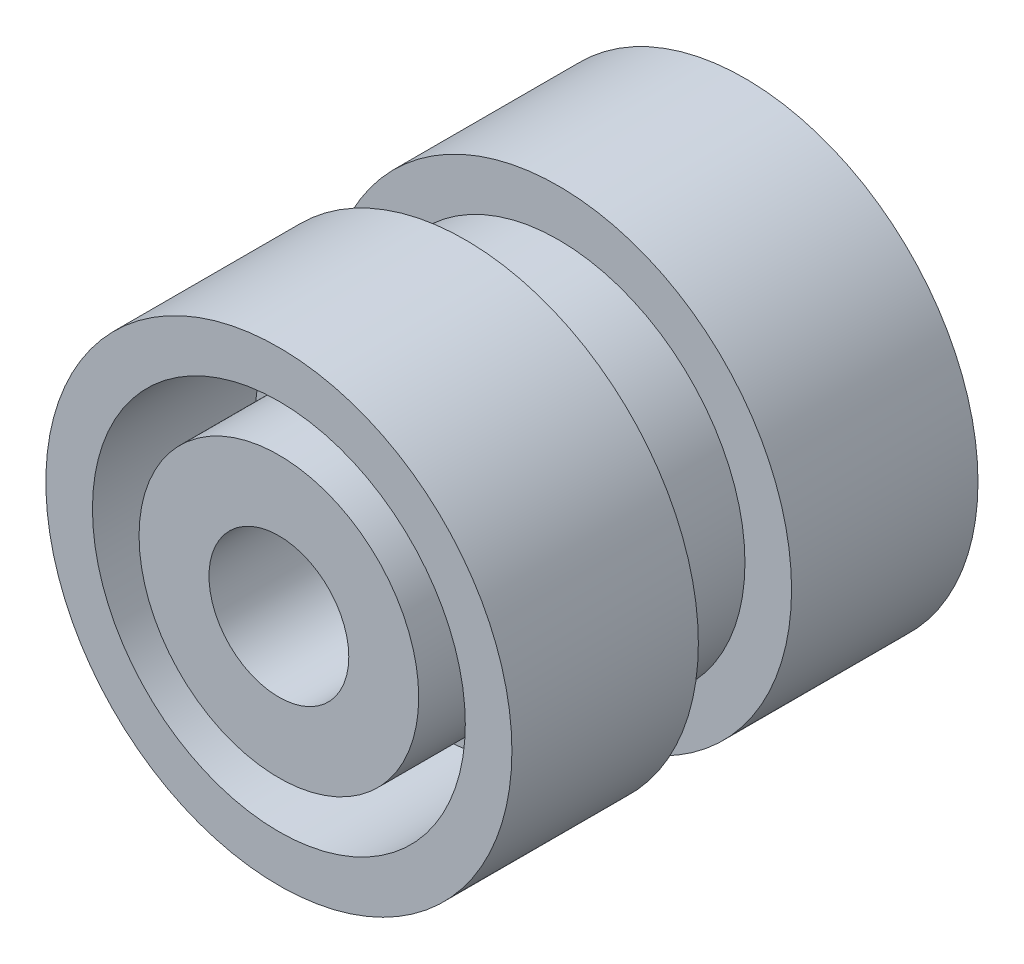
from build123d import *

# Parameters (mm, degrees)
BOSS_EXTRUDE1_DEPTH = 2
SKETCH4_R           = 1.5
CUT_EXTRUDE1_DEPTH  = 8
SCALE1_SCALE        = 2


with BuildPart() as part:
    # Sketch2 → Revolve1 (revolve)
    with BuildSketch(Plane(origin=(0, 0, 0), x_dir=(0, 0, -1), z_dir=(1, 0, 0))):
        Polygon((0, 0), (-5, 0), (-5, 3), (-1.5, 3), (-1.5, 4), (-5, 4), (-5, 5), (-1, 5), (-1, 4), (1, 4), (1, 5), (5, 5), (5, 4), (1.5, 4), (1.5, 0), align=None)
    revolve(axis=Axis((0, 0, 7.547271319), (0, 0, -1)))

    # Sketch3 → Boss-Extrude1 (add)
    with BuildSketch(Plane(origin=(0, 0, -1.5), x_dir=(-1, 0, 0), z_dir=(0, 0, -1))):
        with BuildLine():
            Line((0.5, 1.936491673), (0.5, 3.968626967))
            ThreePointArc((0.5, 3.968626967), (0, 4), (-0.5, 3.968626967))
            Line((-0.5, 3.968626967), (-0.5, 1.936491673))
            ThreePointArc((-0.5, 1.936491673), (-1.414213562, 1.414213562), (-1.936491673, 0.5))
            Line((-1.936491673, 0.5), (-3.968626967, 0.5))
            ThreePointArc((-3.968626967, 0.5), (-4, 0), (-3.968626967, -0.5))
            Line((-3.968626967, -0.5), (-1.936491673, -0.5))
            ThreePointArc((-1.936491673, -0.5), (-1.414213562, -1.414213562), (-0.5, -1.936491673))
            Line((-0.5, -1.936491673), (-0.5, -3.968626967))
            ThreePointArc((-0.5, -3.968626967), (0, -4), (0.5, -3.968626967))
            Line((0.5, -3.968626967), (0.5, -1.936491673))
            ThreePointArc((0.5, -1.936491673), (1.414213562, -1.414213562), (1.936491673, -0.5))
            Line((1.936491673, -0.5), (3.968626967, -0.5))
            ThreePointArc((3.968626967, -0.5), (4, 0), (3.968626967, 0.5))
            Line((3.968626967, 0.5), (1.936491673, 0.5))
            ThreePointArc((1.936491673, 0.5), (1.414213562, 1.414213562), (0.5, 1.936491673))
        make_face()
    extrude(amount=BOSS_EXTRUDE1_DEPTH)

    # Sketch4 → Cut-Extrude1 (cut)
    with BuildSketch(Plane.XY.offset(5)):
        Circle(SKETCH4_R)
    extrude(amount=-CUT_EXTRUDE1_DEPTH, mode=Mode.SUBTRACT)


with BuildPart() as part_1:
    # Scale1: scaled about (0, 0, 0.351761007)
    add(part.part.scale(SCALE1_SCALE).moved(Location((0, 0, -0.351761007))))


solid = part_1.part
